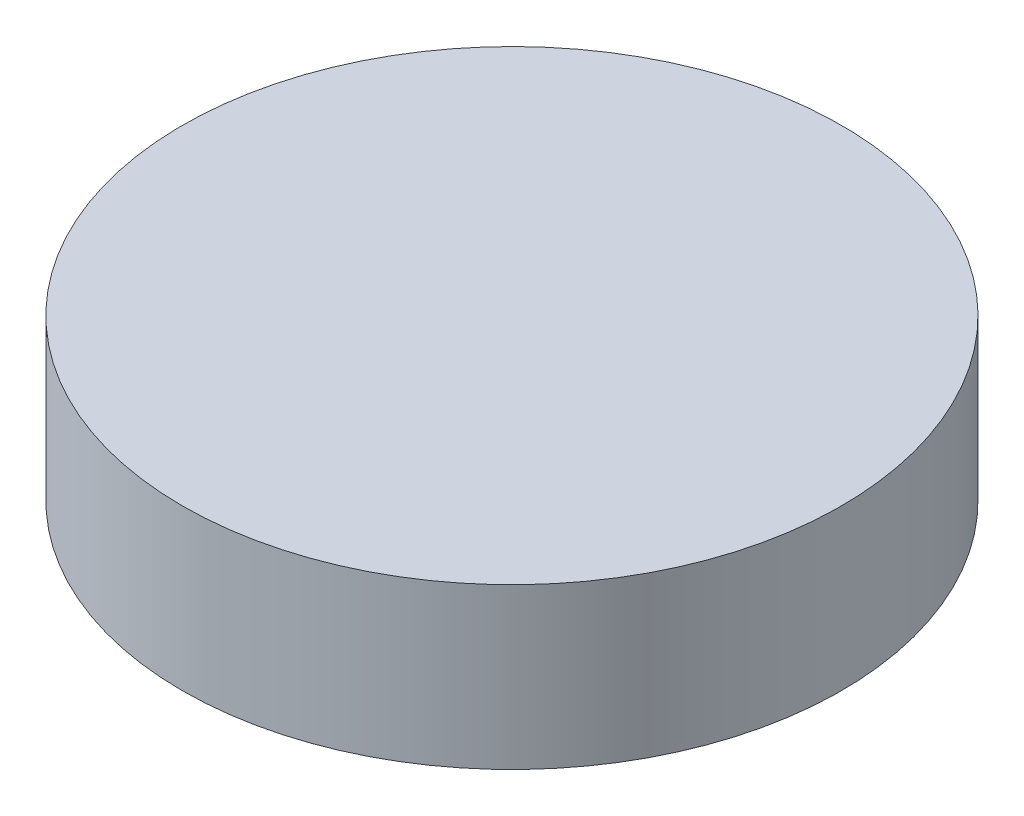
from build123d import *

# Parameters (mm, degrees)
SKETCH1_R           = 20.59
BOSS_EXTRUDE1_DEPTH = 10


with BuildPart() as part:
    # Sketch1 → Boss-Extrude1 (new body)
    with BuildSketch(Plane(origin=(0, 0, 0), x_dir=(1, 0, 0), z_dir=(0, 1, 0))):
        Circle(SKETCH1_R)
    extrude(amount=BOSS_EXTRUDE1_DEPTH)


solid = part.part
